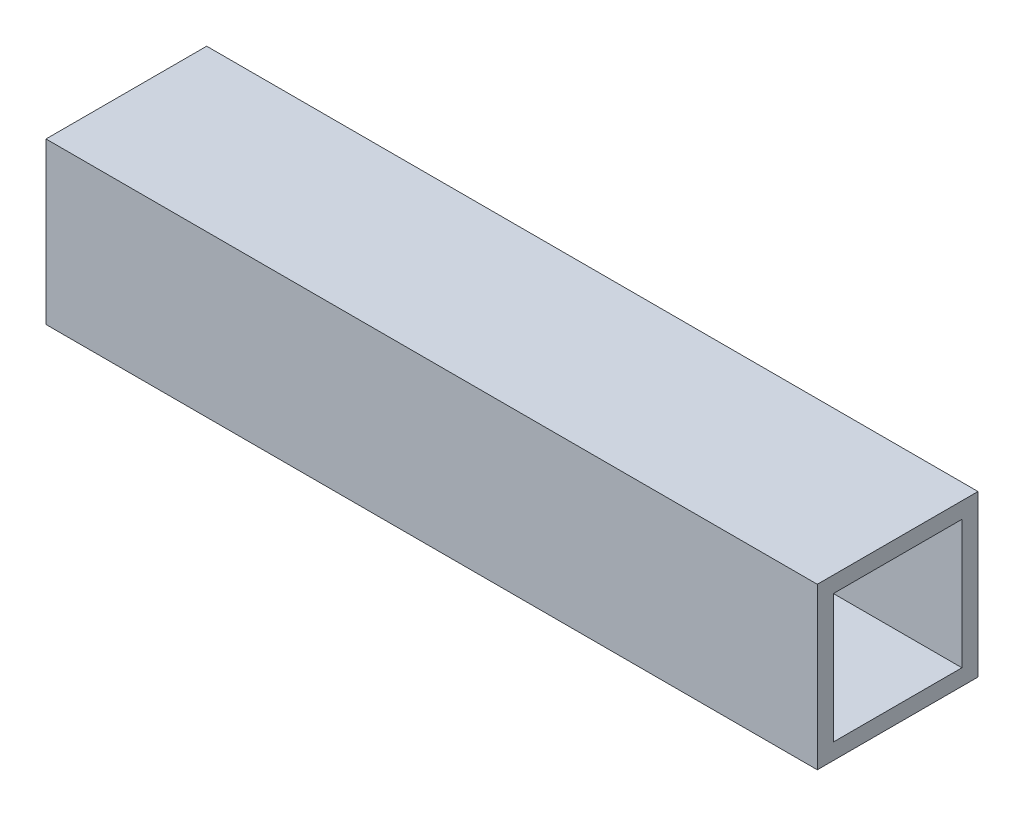
from build123d import *

# Parameters (mm, degrees)
SKETCH1_W           = 63.5
SKETCH1_H           = 63.5
SKETCH1_W_2         = 50.8
SKETCH1_H_2         = 50.8
BOSS_EXTRUDE1_DEPTH = 152.4


with BuildPart() as part:
    # Sketch1 → Boss-Extrude1 (new body, symmetric)
    with BuildSketch(Plane(origin=(0, 0, 0), x_dir=(0, 0, -1), z_dir=(1, 0, 0))):
        Rectangle(SKETCH1_W, SKETCH1_H)
        Rectangle(SKETCH1_W_2, SKETCH1_H_2, mode=Mode.SUBTRACT)
    extrude(amount=BOSS_EXTRUDE1_DEPTH, both=True)


solid = part.part
